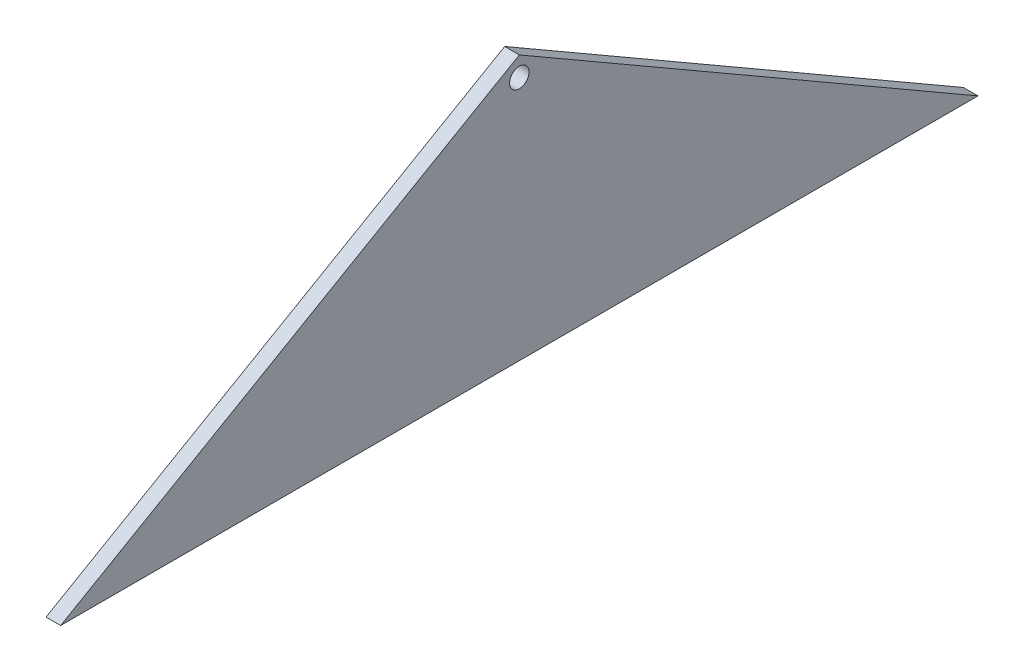
from build123d import *

# Parameters (mm, degrees)
SKETCH1_R           = 2
BOSS_EXTRUDE1_DEPTH = 3


with BuildPart() as part:
    # Sketch1 → Boss-Extrude1 (new body)
    with BuildSketch(Plane(origin=(0, 0, 0), x_dir=(0, 0, -1), z_dir=(1, 0, 0))):
        Polygon((-94, 0), (94, 0), (0, 54.270925304), align=None)
        with Locations((0, 50.270925304)):
            Circle(SKETCH1_R, mode=Mode.SUBTRACT)
    extrude(amount=BOSS_EXTRUDE1_DEPTH)


solid = part.part
